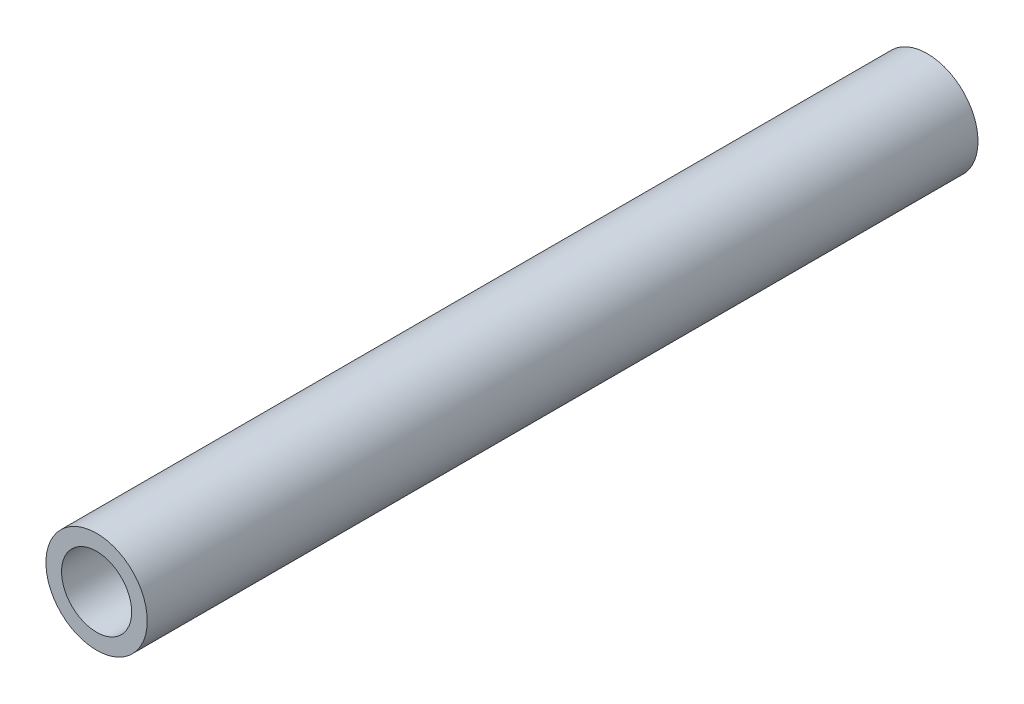
from build123d import *

# Parameters (mm, degrees)
SKETCH1_R           = 7.747
SKETCH1_R_2         = 5.3594
BOSS_EXTRUDE1_DEPTH = 127


with BuildPart() as part:
    # Sketch1 → Boss-Extrude1 (new body)
    with BuildSketch(Plane.XY):
        Circle(SKETCH1_R)
        Circle(SKETCH1_R_2, mode=Mode.SUBTRACT)
    extrude(amount=BOSS_EXTRUDE1_DEPTH)


solid = part.part
